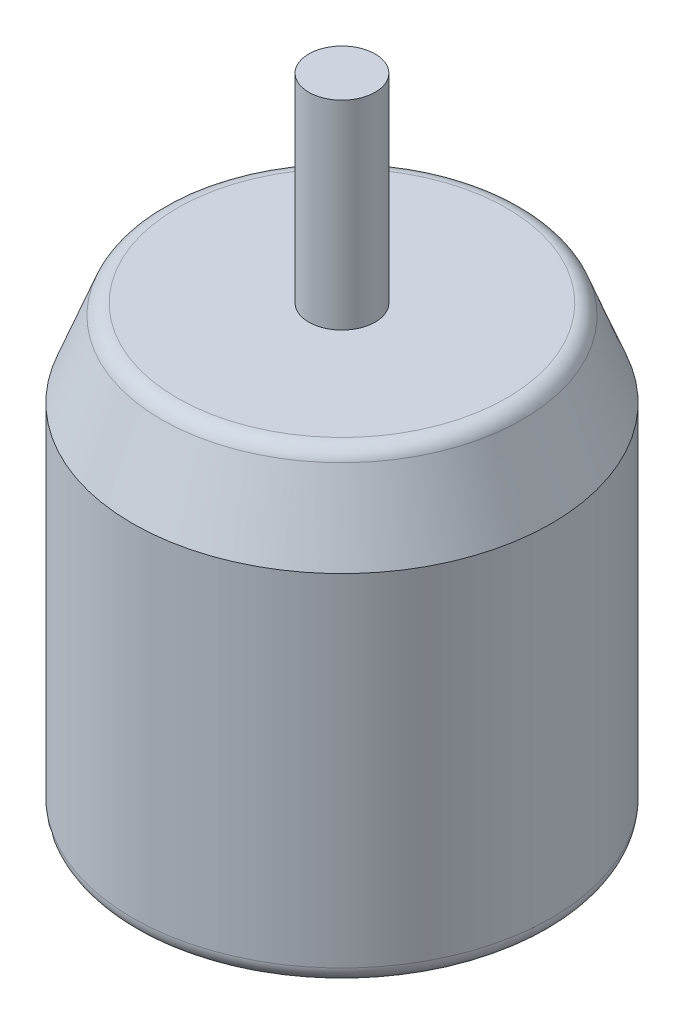
from build123d import *

# Parameters (mm, degrees)
SKETCH3_R           = 31.55
BOSS_EXTRUDE1_DEPTH = 13
SKETCH6_R           = 31.55
BOSS_EXTRUDE2_DEPTH = 54
FILLET1_R           = 2.54
SKETCH7_R           = 5
BOSS_EXTRUDE3_DEPTH = 30


with BuildPart() as part:
    # Sketch3 → Boss-Extrude1 (new body)
    with BuildSketch(Plane(origin=(0, 0, 0), x_dir=(1, 0, 0), z_dir=(0, 1, 0))):
        Circle(SKETCH3_R)
    extrude(amount=BOSS_EXTRUDE1_DEPTH)

    # Sketch5 → Cut-Revolve1 (revolve, cut)
    with BuildSketch(Plane.XY):
        Polygon((31.55, 13), (26.55, 13), (31.55, 0), align=None)
    revolve(axis=Axis((0, 13, 0), (0, -1, 0)), mode=Mode.SUBTRACT)

    # Sketch6 → Boss-Extrude2 (add)
    with BuildSketch(Plane.XZ):
        Circle(SKETCH6_R)
    extrude(amount=BOSS_EXTRUDE2_DEPTH)

    # Fillet1
    fillet1_edges = [part.edges().sort_by_distance(p)[0] for p in [
        (-31.55, -54, 0),
        (-26.55, 13, 0),
    ]]
    fillet(fillet1_edges, radius=FILLET1_R)

    # Sketch7 → Boss-Extrude3 (add)
    with BuildSketch(Plane(origin=(0, 13, 0), x_dir=(1, 0, 0), z_dir=(0, 1, 0))):
        Circle(SKETCH7_R)
    extrude(amount=BOSS_EXTRUDE3_DEPTH)


solid = part.part
